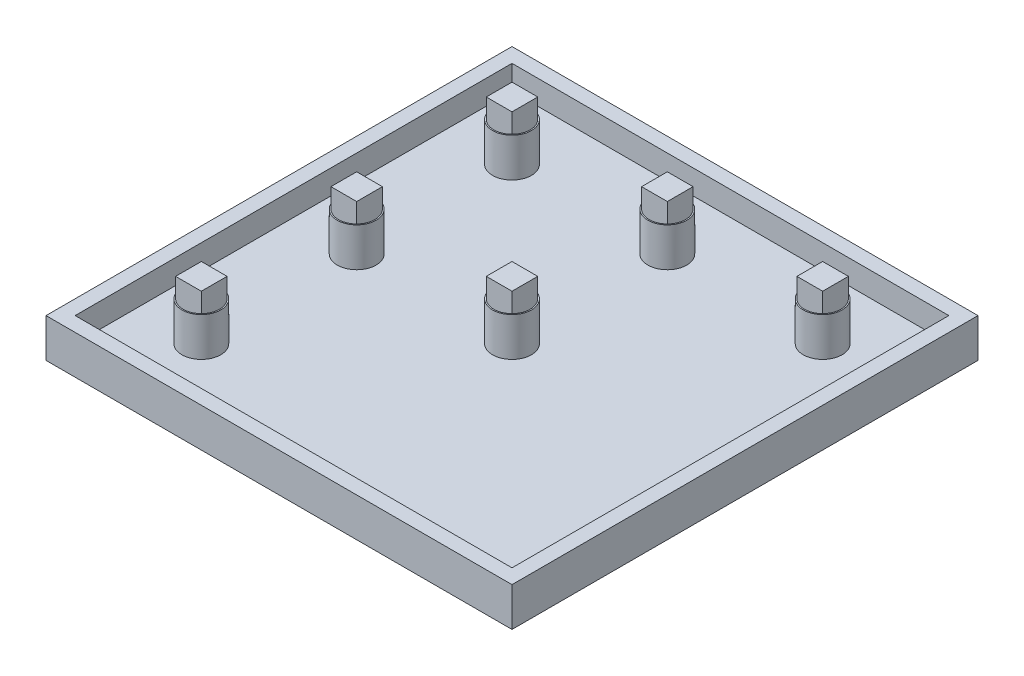
from build123d import *

# Parameters (mm, degrees)
SKETCH1_W            = 1219.2
SKETCH1_H            = 1219.2
BOSS_EXTRUDE1_DEPTH  = 101.6
SHELL2_T             = -38.1
SKETCH3_R            = 50.8
BOSS_EXTRUDE5_DEPTH  = 101.6
SHELL3_T             = -3.175
SKETCH4_W            = 67.39381574
SKETCH4_H            = 67.31
BOSS_EXTRUDE7_DEPTH  = 50.8
SKETCH5_W            = 67.313653798
SKETCH5_H            = 67.39016629
BOSS_EXTRUDE8_DEPTH  = 50.8
SKETCH6_W            = 67.31
SKETCH6_H            = 67.39381574
BOSS_EXTRUDE9_DEPTH  = 50.8
SKETCH8_W            = 67.357659714
SKETCH8_H            = 67.346181614
BOSS_EXTRUDE10_DEPTH = 50.8
SKETCH9_W            = 67.419789214
SKETCH9_H            = 67.283984144
BOSS_EXTRUDE11_DEPTH = 50.8
SKETCH10_W           = 67.32527743
SKETCH10_H           = 67.37855385
BOSS_EXTRUDE12_DEPTH = 50.8


with BuildPart() as part:
    # Sketch1 → Boss-Extrude1 (new body)
    with BuildSketch(Plane(origin=(0, 0, 0), x_dir=(1, 0, 0), z_dir=(0, 1, 0))):
        with Locations((609.6, 609.6)):
            Rectangle(SKETCH1_W, SKETCH1_H)
    extrude(amount=BOSS_EXTRUDE1_DEPTH)

    # Shell2
    shell2_openings = [part.faces().sort_by_distance(p)[0] for p in [
        (609.6, 101.6, -609.6),
    ]]
    offset(amount=SHELL2_T, openings=shell2_openings, kind=Kind.INTERSECTION)

    # Sketch3 → Boss-Extrude5 (add)
    with BuildSketch(Plane(origin=(0, 38.1, 0), x_dir=(1, 0, 0), z_dir=(0, 1, 0))):
        with Locations(Location((203.2, 1016, 0), (0, 0, 90))):  # turned: the seam where the file's is
            Circle(SKETCH3_R)
        with Locations(Location((609.6, 1016, 0), (0, 0, 90))):  # turned: the seam where the file's is
            Circle(SKETCH3_R)
        with Locations(Location((1016, 1016, 0), (0, 0, 90))):  # turned: the seam where the file's is
            Circle(SKETCH3_R)
        with Locations(Location((203.2, 609.6, 0), (0, 0, 90))):  # turned: the seam where the file's is
            Circle(SKETCH3_R)
        with Locations(Location((609.6, 609.6, 0), (0, 0, 90))):  # turned: the seam where the file's is
            Circle(SKETCH3_R)
        with Locations(Location((203.2, 203.2, 0), (0, 0, 90))):  # turned: the seam where the file's is
            Circle(SKETCH3_R)
    extrude(amount=BOSS_EXTRUDE5_DEPTH)

    # Shell3
    shell3_openings = [part.faces().sort_by_distance(p)[0] for p in [
        (203.2, 139.7, -1016),
        (609.6, 139.7, -1016),
        (1016, 139.7, -1016),
        (203.2, 139.7, -609.6),
        (609.6, 139.7, -609.6),
        (203.2, 139.7, -203.2),
    ]]
    offset(amount=SHELL3_T, openings=shell3_openings, kind=Kind.INTERSECTION)


with BuildPart() as body_2:
    # Sketch4 → Boss-Extrude7 (new body, symmetric)
    with BuildSketch(Plane(origin=(0, 139.7, 0), x_dir=(1, 0, 0), z_dir=(0, 1, 0))):
        with Locations((203.2, 609.6)):
            Rectangle(SKETCH4_W, SKETCH4_H)
    extrude(amount=BOSS_EXTRUDE7_DEPTH, both=True)


with BuildPart() as body_3:
    # Sketch5 → Boss-Extrude8 (new body, symmetric)
    with BuildSketch(Plane(origin=(0, 139.7, 0), x_dir=(1, 0, 0), z_dir=(0, 1, 0))):
        with Locations((203.2, 203.2)):
            Rectangle(SKETCH5_W, SKETCH5_H)
    extrude(amount=BOSS_EXTRUDE8_DEPTH, both=True)


with BuildPart() as body_4:
    # Sketch6 → Boss-Extrude9 (new body, symmetric)
    with BuildSketch(Plane(origin=(0, 139.7, 0), x_dir=(1, 0, 0), z_dir=(0, 1, 0))):
        with Locations((203.2, 1016)):
            Rectangle(SKETCH6_W, SKETCH6_H)
    extrude(amount=BOSS_EXTRUDE9_DEPTH, both=True)


with BuildPart() as body_5:
    # Sketch8 → Boss-Extrude10 (new body, symmetric)
    with BuildSketch(Plane(origin=(0, 139.7, 0), x_dir=(1, 0, 0), z_dir=(0, 1, 0))):
        with Locations((609.6, 1016)):
            Rectangle(SKETCH8_W, SKETCH8_H)
    extrude(amount=BOSS_EXTRUDE10_DEPTH, both=True)


with BuildPart() as body_6:
    # Sketch9 → Boss-Extrude11 (new body, symmetric)
    with BuildSketch(Plane(origin=(0, 139.7, 0), x_dir=(1, 0, 0), z_dir=(0, 1, 0))):
        with Locations((609.6, 609.6)):
            Rectangle(SKETCH9_W, SKETCH9_H)
    extrude(amount=BOSS_EXTRUDE11_DEPTH, both=True)


with BuildPart() as body_7:
    # Sketch10 → Boss-Extrude12 (new body, symmetric)
    with BuildSketch(Plane(origin=(0, 139.7, 0), x_dir=(1, 0, 0), z_dir=(0, 1, 0))):
        with Locations((1016, 1016)):
            Rectangle(SKETCH10_W, SKETCH10_H)
    extrude(amount=BOSS_EXTRUDE12_DEPTH, both=True)


solid = Compound([part.part, body_2.part, body_3.part, body_4.part, body_5.part, body_6.part, body_7.part])
